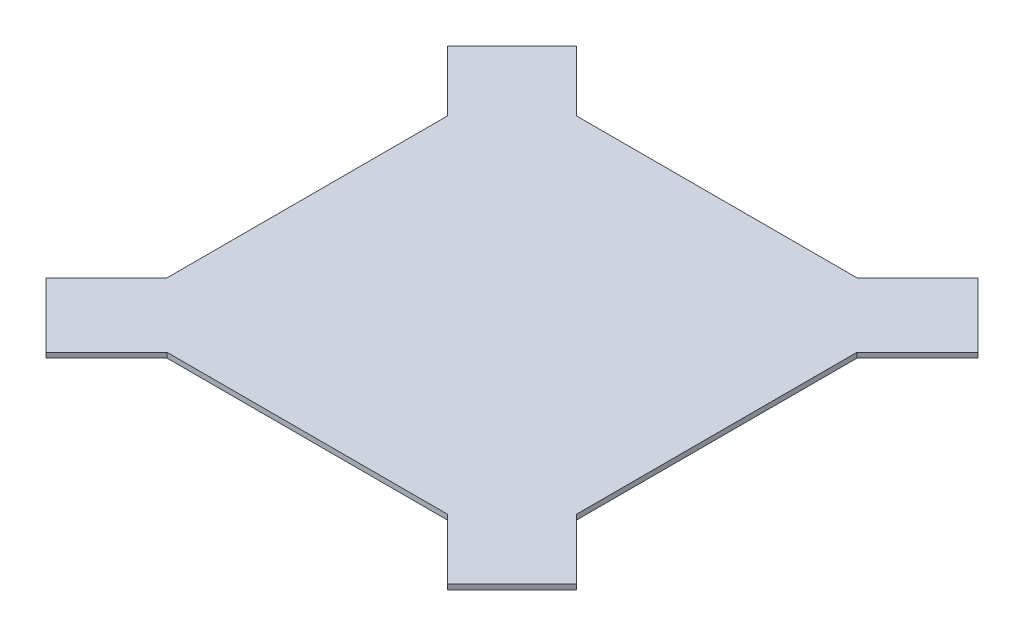
from build123d import *

# Parameters (mm, degrees)
BOSS_EXTRUDE1_DEPTH     = 6.35
CUT_EXTRUDE1_REACH      = 540.853
SKETCH3_R               = 48.260000044
MIRROR2_COPY_1_REACH    = 540.853
MIRROR2_COPY_1_SKETCH_R = 48.260000044
MIRROR2_COPY_2_REACH    = 540.853
MIRROR2_COPY_2_SKETCH_R = 48.260000044
BOSS_EXTRUDE3_START     = -6.35
BOSS_EXTRUDE3_DEPTH     = 6.35
CUT_EXTRUDE12_START     = -55.372
CUT_EXTRUDE12_DEPTH     = 55.372


with BuildPart() as part:
    # Sketch1 → Boss-Extrude1 (new body)
    with BuildSketch(Plane(origin=(0, 0, 0), x_dir=(1, 0, 0), z_dir=(0, 1, 0))):
        Polygon((-254, -381), (254, -381), (381, -254), (381, 254), (254, 381), (-254, 381), (-381, 254), (-381, -254), align=None)
    extrude(amount=-BOSS_EXTRUDE1_DEPTH)

    # Sketch3 → Cut-Extrude1 (cut, up to next)
    with BuildSketch(Plane(origin=(0, 0, 0), x_dir=(1, 0, 0), z_dir=(0, 1, 0)), mode=Mode.PRIVATE) as cut_extrude1_sk1:
        with BuildLine():
            Line((-175.260000044, -256.082305134), (-251.046104704, -331.868409794))
            Line((-251.046104704, -331.868409794), (-331.868409794, -251.046104704))
            Line((-331.868409794, -251.046104704), (-256.082305134, -175.260000044))
            Line((-256.082305134, -175.260000044), (-256.082305134, 0))
            Line((-256.082305134, 0), (-381, 0))
            Line((-381, 0), (-381, -254))
            Line((-381, -254), (-254, -381))
            Line((-254, -381), (0, -381))
            Line((0, -381), (0, -256.082305134))
            Line((0, -256.082305134), (-66.039999956, -256.082305134))
            Line((-66.039999956, -256.082305134), (-66.039999956, -279.4))
            ThreePointArc((-66.039999956, -279.4), (-120.65, -334.010000044), (-175.260000044, -279.4))
            Line((-175.260000044, -279.4), (-175.260000044, -256.082305134))
        make_face()
    cut_extrude1_tool1 = extrude(cut_extrude1_sk1.sketch, amount=-CUT_EXTRUDE1_REACH, mode=Mode.PRIVATE) & part.part
    # Sketch3 → Cut-Extrude1 (cut, up to next)
    with BuildSketch(Plane(origin=(0, 0, 0), x_dir=(1, 0, 0), z_dir=(0, 1, 0)), mode=Mode.PRIVATE) as cut_extrude1_sk2:
        with Locations((-120.65, -279.4)):
            Circle(SKETCH3_R)
    cut_extrude1_tool2 = extrude(cut_extrude1_sk2.sketch, amount=-CUT_EXTRUDE1_REACH, mode=Mode.PRIVATE) & part.part
    cut_extrude1_1 = cut_extrude1_tool1.solids().sort_by_distance((-180.648154, 0, 267.741153))[0]
    add(cut_extrude1_1, mode=Mode.SUBTRACT)
    cut_extrude1_2 = cut_extrude1_tool2.solids().sort_by_distance((-120.65, 0, 279.4))[0]
    add(cut_extrude1_2, mode=Mode.SUBTRACT)
    cut_extrude1 = cut_extrude1_1 + cut_extrude1_2  # Cut-Extrude1 as one shape, for the pattern or mirror that repeats it

    # Mirror1: Cut-Extrude1 across plane
    add(cut_extrude1.mirror(Plane(origin=(0, 0, 0), x_dir=(0, 0, 1), z_dir=(1, 0, 0))), mode=Mode.SUBTRACT)

    # Mirror2 copy 1 sketch → Mirror2 copy 1 (cut, up to next)
    with BuildSketch(Plane(origin=(0, 0, 0), x_dir=(-1, 0, 0), z_dir=(0, 1, 0)), mode=Mode.PRIVATE) as mirror2_copy_1_sk1:
        with BuildLine():
            Line((-175.260000044, -256.082305134), (-251.046104704, -331.868409794))
            Line((-251.046104704, -331.868409794), (-331.868409794, -251.046104704))
            Line((-331.868409794, -251.046104704), (-256.082305134, -175.260000044))
            Line((-256.082305134, -175.260000044), (-256.082305134, 0))
            Line((-256.082305134, 0), (-381, 0))
            Line((-381, 0), (-381, -254))
            Line((-381, -254), (-254, -381))
            Line((-254, -381), (0, -381))
            Line((0, -381), (0, -256.082305134))
            Line((0, -256.082305134), (-66.039999956, -256.082305134))
            Line((-66.039999956, -256.082305134), (-66.039999956, -279.4))
            ThreePointArc((-66.039999956, -279.4), (-120.65, -334.010000044), (-175.260000044, -279.4))
            Line((-175.260000044, -279.4), (-175.260000044, -256.082305134))
        make_face()
    mirror2_copy_1_tool1 = extrude(mirror2_copy_1_sk1.sketch, amount=-MIRROR2_COPY_1_REACH, mode=Mode.PRIVATE) & part.part
    # Mirror2 copy 1 sketch → Mirror2 copy 1 (cut, up to next)
    with BuildSketch(Plane(origin=(0, 0, 0), x_dir=(-1, 0, 0), z_dir=(0, 1, 0)), mode=Mode.PRIVATE) as mirror2_copy_1_sk2:
        with Locations((-120.65, -279.4)):
            Circle(MIRROR2_COPY_1_SKETCH_R)
    mirror2_copy_1_tool2 = extrude(mirror2_copy_1_sk2.sketch, amount=-MIRROR2_COPY_1_REACH, mode=Mode.PRIVATE) & part.part
    add(mirror2_copy_1_tool1.solids().sort_by_distance((180.648154, 0, -267.741153))[0], mode=Mode.SUBTRACT)
    add(mirror2_copy_1_tool2.solids().sort_by_distance((120.65, 0, -279.4))[0], mode=Mode.SUBTRACT)

    # Mirror2 copy 2 sketch → Mirror2 copy 2 (cut, up to next)
    with BuildSketch(Plane(origin=(0, 0, 0), x_dir=(1, 0, 0), z_dir=(0, 1, 0)), mode=Mode.PRIVATE) as mirror2_copy_2_sk1:
        with BuildLine():
            Line((-175.260000044, 256.082305134), (-251.046104704, 331.868409794))
            Line((-251.046104704, 331.868409794), (-331.868409794, 251.046104704))
            Line((-331.868409794, 251.046104704), (-256.082305134, 175.260000044))
            Line((-256.082305134, 175.260000044), (-256.082305134, 0))
            Line((-256.082305134, 0), (-381, 0))
            Line((-381, 0), (-381, 254))
            Line((-381, 254), (-254, 381))
            Line((-254, 381), (0, 381))
            Line((0, 381), (0, 256.082305134))
            Line((0, 256.082305134), (-66.039999956, 256.082305134))
            Line((-66.039999956, 256.082305134), (-66.039999956, 279.4))
            ThreePointArc((-66.039999956, 279.4), (-120.65, 334.010000044), (-175.260000044, 279.4))
            Line((-175.260000044, 279.4), (-175.260000044, 256.082305134))
        make_face()
    mirror2_copy_2_tool1 = extrude(mirror2_copy_2_sk1.sketch, amount=-MIRROR2_COPY_2_REACH, mode=Mode.PRIVATE) & part.part
    # Mirror2 copy 2 sketch → Mirror2 copy 2 (cut, up to next)
    with BuildSketch(Plane(origin=(0, 0, 0), x_dir=(1, 0, 0), z_dir=(0, 1, 0)), mode=Mode.PRIVATE) as mirror2_copy_2_sk2:
        with Locations((-120.65, 279.4)):
            Circle(MIRROR2_COPY_2_SKETCH_R)
    mirror2_copy_2_tool2 = extrude(mirror2_copy_2_sk2.sketch, amount=-MIRROR2_COPY_2_REACH, mode=Mode.PRIVATE) & part.part
    add(mirror2_copy_2_tool1.solids().sort_by_distance((-180.648154, 0, -267.741153))[0], mode=Mode.SUBTRACT)
    add(mirror2_copy_2_tool2.solids().sort_by_distance((-120.65, 0, -279.4))[0], mode=Mode.SUBTRACT)

    # Sketch39 → Boss-Extrude3 (add)
    with BuildSketch(Plane.XZ.offset(6.35).offset(BOSS_EXTRUDE3_START)):
        with BuildLine():
            Line((78.397039034, -256.082305134), (162.902960966, -256.082305134))
            ThreePointArc((162.902960966, -256.082305134), (120.65, -231.139999956), (78.397039034, -256.082305134))
        make_face()
        with BuildLine():
            Line((-162.902960966, -256.082305134), (-78.397039034, -256.082305134))
            ThreePointArc((-78.397039034, -256.082305134), (-120.65, -231.139999956), (-162.902960966, -256.082305134))
        make_face()
    boss_extrude3 = extrude(amount=BOSS_EXTRUDE3_DEPTH)

    # Sketch39_3 → Cut-Extrude12 (cut)
    with BuildSketch(Plane.XZ.offset(6.35).offset(CUT_EXTRUDE12_START)):
        with BuildLine():
            Line((78.397039034, -256.082305134), (66.039999956, -256.082305134))
            Line((66.039999956, -256.082305134), (66.039999956, -279.4))
            ThreePointArc((66.039999956, -279.4), (120.65, -334.010000044), (175.260000044, -279.4))
            Line((175.260000044, -279.4), (175.260000044, -256.082305134))
            Line((175.260000044, -256.082305134), (162.902960966, -256.082305134))
            ThreePointArc((162.902960966, -256.082305134), (120.65, -327.660000044), (78.397039034, -256.082305134))
        make_face()
        with BuildLine():
            Line((-66.039999956, -279.4), (-66.039999956, -256.082305134))
            Line((-66.039999956, -256.082305134), (-78.397039034, -256.082305134))
            ThreePointArc((-78.397039034, -256.082305134), (-120.65, -327.660000044), (-162.902960966, -256.082305134))
            Line((-162.902960966, -256.082305134), (-175.260000044, -256.082305134))
            Line((-175.260000044, -256.082305134), (-175.260000044, -279.4))
            ThreePointArc((-175.260000044, -279.4), (-120.65, -334.010000044), (-66.039999956, -279.4))
        make_face()
    cut_extrude12 = extrude(amount=CUT_EXTRUDE12_DEPTH, mode=Mode.SUBTRACT)

    # Mirror9: Boss-Extrude3, Cut-Extrude12 across plane
    add(boss_extrude3.mirror(Plane.XY))
    add(cut_extrude12.mirror(Plane.XY), mode=Mode.SUBTRACT)


solid = part.part
